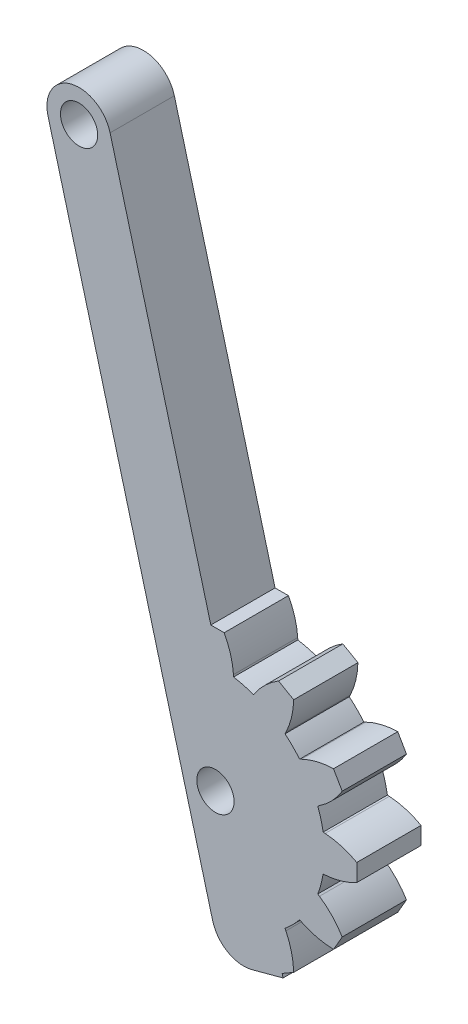
from build123d import *

# Parameters (mm, degrees)
SKETCH1_R           = 1.45
BOSS_EXTRUDE1_DEPTH = 5


with BuildPart() as part:
    # Sketch1 → Boss-Extrude1 (new body)
    with BuildSketch(Plane.XY.offset(1.9)):
        with BuildLine():
            Line((-13.026395415, 38.955911265), (-0.214852682, -8.857417136))
            ThreePointArc((-0.214852682, -8.857417136), (0.949961883, -10.375433033), (2.847009496, -10.625184089))
            Line((2.847009496, -10.625184089), (5.261824062, -9.978136476))
            Line((5.261824062, -9.978136476), (5.188879797, -9.705904774))
            Line((5.188879797, -9.705904774), (6.08761429, -9.187020173))
            ThreePointArc((6.08761429, -9.187020173), (5.919814799, -7.906537121), (5.481893659, -6.691622066))
            Line((5.481893659, -6.691622066), (5.414116812, -6.552658937))
            ThreePointArc((5.414116812, -6.552658937), (6.01040764, -6.01040764), (6.552658937, -5.414116812))
            Line((6.552658937, -5.414116812), (6.691622066, -5.481893659))
            ThreePointArc((6.691622066, -5.481893659), (7.906537121, -5.919814799), (9.187020173, -6.08761429))
            Line((9.187020173, -6.08761429), (9.86553871, -4.91238571))
            ThreePointArc((9.86553871, -4.91238571), (9.079978562, -3.887354604), (8.093270203, -3.054167872))
            Line((8.093270203, -3.054167872), (7.965092167, -2.967710696))
            ThreePointArc((7.965092167, -2.967710696), (8.210369523, -2.199961883), (8.381827508, -1.41243323))
            Line((8.381827508, -1.41243323), (8.536061531, -1.401648137))
            ThreePointArc((8.536061531, -1.401648137), (9.807169402, -1.173441441), (11, -0.678518537))
            Line((11, -0.678518537), (11, 0.678518537))
            ThreePointArc((11, 0.678518537), (9.807169402, 1.173441441), (8.536061531, 1.401648137))
            Line((8.536061531, 1.401648137), (8.381827508, 1.41243323))
            ThreePointArc((8.381827508, 1.41243323), (8.210369523, 2.199961883), (7.965092167, 2.967710696))
            Line((7.965092167, 2.967710696), (8.093270203, 3.054167872))
            ThreePointArc((8.093270203, 3.054167872), (9.079978562, 3.887354604), (9.86553871, 4.91238571))
            Line((9.86553871, 4.91238571), (9.187020173, 6.08761429))
            ThreePointArc((9.187020173, 6.08761429), (7.906537121, 5.919814799), (6.691622066, 5.481893659))
            Line((6.691622066, 5.481893659), (6.552658937, 5.414116812))
            ThreePointArc((6.552658937, 5.414116812), (6.01040764, 6.01040764), (5.414116812, 6.552658937))
            Line((5.414116812, 6.552658937), (5.481893659, 6.691622066))
            ThreePointArc((5.481893659, 6.691622066), (5.919814799, 7.906537121), (6.08761429, 9.187020173))
            Line((6.08761429, 9.187020173), (4.91238571, 9.86553871))
            ThreePointArc((4.91238571, 9.86553871), (3.887354604, 9.079978562), (3.054167872, 8.093270203))
            Line((3.054167872, 8.093270203), (2.967710696, 7.965092167))
            ThreePointArc((2.967710696, 7.965092167), (2.199961883, 8.210369523), (1.41243323, 8.381827508))
            Line((1.41243323, 8.381827508), (1.401648136, 8.536061531))
            ThreePointArc((1.401648136, 8.536061531), (1.173441441, 9.807169402), (0.678518537, 11))
            Line((0.678518537, 11), (-0.359250666, 11))
            Line((-0.359250666, 11), (-8.196766283, 40.250006491))
            ThreePointArc((-8.196766283, 40.250006491), (-11.258628462, 42.017773444), (-13.026395415, 38.955911265))
        make_face()
        with Locations((-10.611580849, 39.602958878)):
            Circle(SKETCH1_R, mode=Mode.SUBTRACT)
        Circle(SKETCH1_R, mode=Mode.SUBTRACT)
    extrude(amount=-BOSS_EXTRUDE1_DEPTH)


solid = part.part
